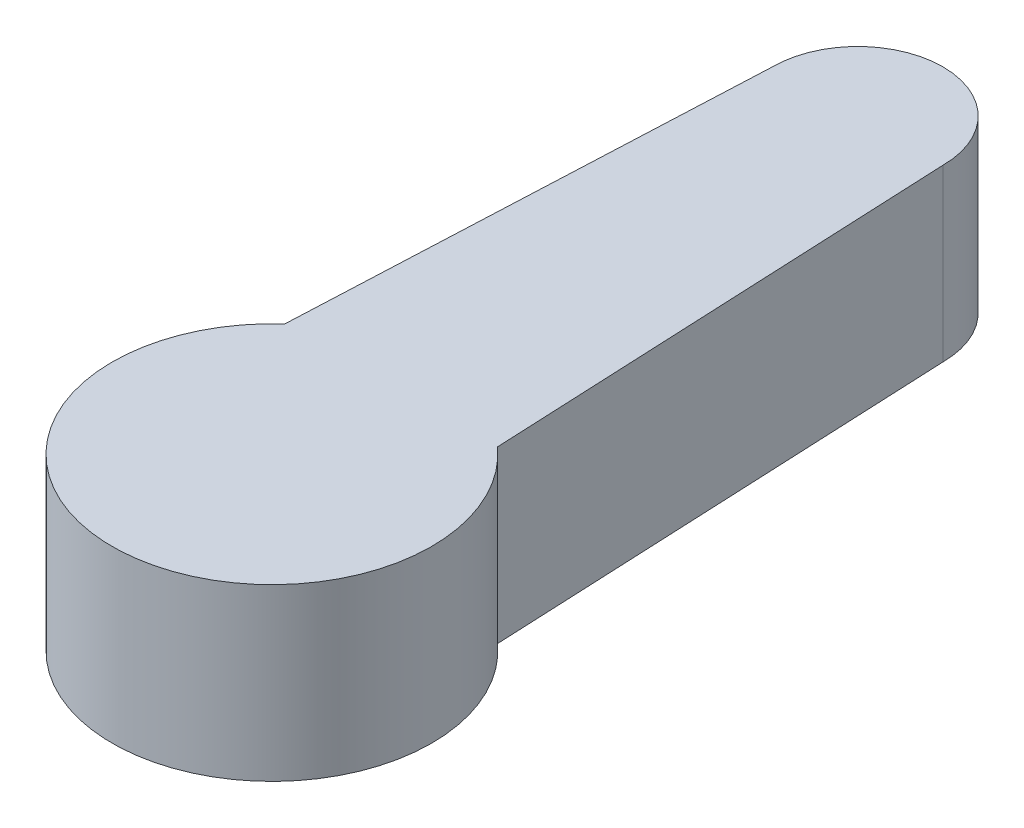
from build123d import *

# Parameters (mm, degrees)
BOSS_EXTRUDE1_DEPTH = 4


with BuildPart() as part:
    # Sketch1 → Boss-Extrude1 (new body)
    with BuildSketch(Plane(origin=(0, 0, 0), x_dir=(1, 0, 0), z_dir=(0, 1, 0))):
        with BuildLine():
            ThreePointArc((2, 13.75), (0, 15.75), (-2, 13.75))
            Line((-2, 13.75), (-2.497863905, 2.796994085))
            ThreePointArc((-2.497863905, 2.796994085), (0, -3.75), (2.497863905, 2.796994085))
            Line((2.497863905, 2.796994085), (2, 13.75))
        make_face()
    extrude(amount=BOSS_EXTRUDE1_DEPTH)


solid = part.part
